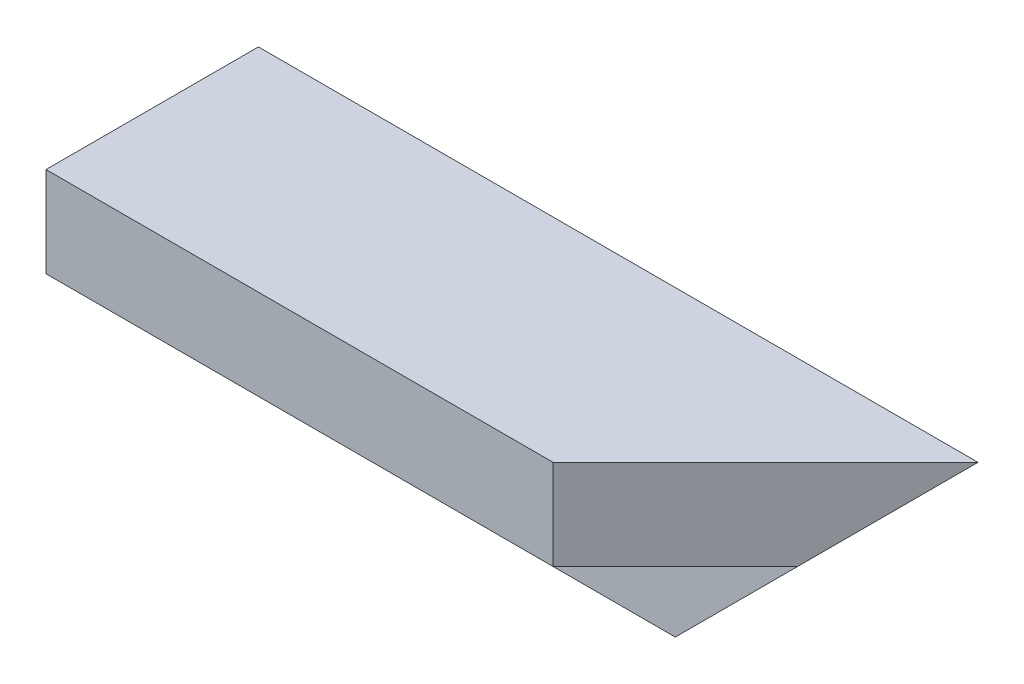
from build123d import *

# Parameters (mm, degrees)
BOSS_EXTRU_1_START      = 86.5
BOSS_EXTRU_1_DEPTH      = 135.5
ENL_V_MAT_EXTRU_1_DEPTH = 41
ENL_V_MAT_EXTRU_2_DEPTH = 41


with BuildPart() as part:
    # Esquisse1 → Boss.-Extru.1 (new body)
    with BuildSketch(Plane(origin=(0, 0, 0), x_dir=(0, 0, -1), z_dir=(1, 0, 0)).offset(BOSS_EXTRU_1_START)):
        Polygon((0, 0), (-40, 0), (-40, -17), (-17, -17), (-17, -40), (0, -40), align=None)
    extrude(amount=BOSS_EXTRU_1_DEPTH)

    # Esquisse2 → Enlèv. mat.-Extru.1 (cut, through all)
    with BuildSketch(Plane(origin=(0, 0, 0), x_dir=(1, 0, 0), z_dir=(0, 1, 0))):
        Polygon((222, 0), (182, -40), (222, -40), align=None)
    extrude(amount=-ENL_V_MAT_EXTRU_1_DEPTH, mode=Mode.SUBTRACT)

    # Esquisse3 → Enlèv. mat.-Extru.2 (cut, through all)
    with BuildSketch(Plane(origin=(0, 0, 0), x_dir=(-1, 0, 0), z_dir=(0, 0, -1))):
        Polygon((-222, 0), (-182, -40), (-222, -40), align=None)
    extrude(amount=-ENL_V_MAT_EXTRU_2_DEPTH, mode=Mode.SUBTRACT)


solid = part.part
